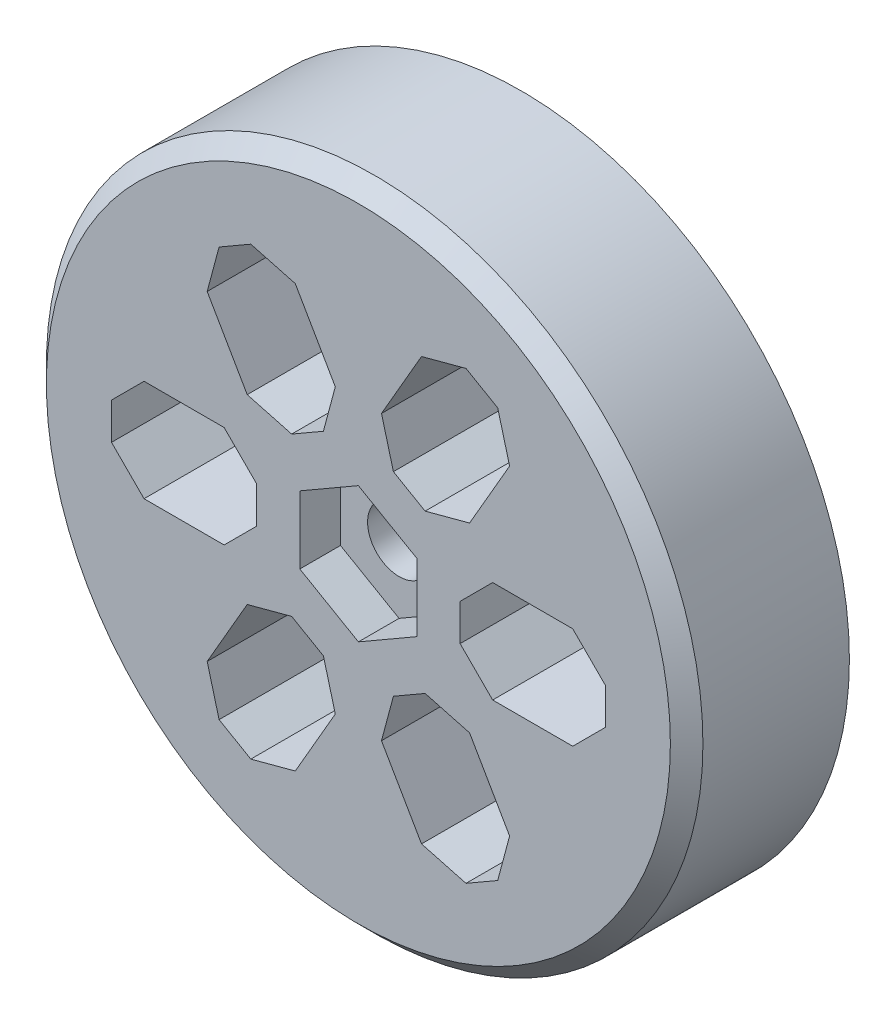
from build123d import *

# Parameters (mm, degrees)
SKETCH1_R               = 25.6159
BOSS_EXTRUDE1_DEPTH     = 12.7
CHAMFER1_SIZE           = 1.27
CUT_EXTRUDE1_DEPTH      = 3.175
F_8_CLEARANCE_HOLE1_D   = 4.9149
SKETCH5_W               = 11.3284
SKETCH5_H               = 7.9375
CUT_EXTRUDE_THIN1_DEPTH = 13.7
CHAMFER2_SIZE           = 2.54


with BuildPart() as part:
    # Sketch1 → Boss-Extrude1 (new body)
    with BuildSketch(Plane.XY):
        Circle(SKETCH1_R)
    extrude(amount=BOSS_EXTRUDE1_DEPTH)

    # Chamfer1
    chamfer1_edges = [part.edges().sort_by_distance(p)[0] for p in [
        (-25.6159, 0, 12.7),
    ]]
    chamfer(chamfer1_edges, length=CHAMFER1_SIZE)

    # Sketch2 → Cut-Extrude1 (cut)
    with BuildSketch(Plane.XY.offset(12.7)):
        Polygon((-4.572, -2.639645431), (0, -5.279290861), (4.572, -2.639645431), (4.572, 2.639645431), (0, 5.279290861), (-4.572, 2.639645431), align=None)
    extrude(amount=-CUT_EXTRUDE1_DEPTH, mode=Mode.SUBTRACT)

    # #8 Clearance Hole1 (through all)
    with Locations(Plane.XY.offset(12.7)):
        with Locations((0, 0)):
            Hole(F_8_CLEARANCE_HOLE1_D / 2)

    # Sketch5 → Cut-Extrude-Thin1 (cut, through all)
    with BuildSketch(Plane.XY.offset(12.7)):
        Polygon((-7.405788321, -4.889701643), (-13.069988321, -14.700383827), (-6.195911679, -18.669133827), (-0.531711679, -8.858451643), align=None)
        with Locations((-13.6017, 0)):
            Rectangle(SKETCH5_W, SKETCH5_H)
        Polygon((-0.531711679, 8.858451643), (-6.195911679, 18.669133827), (-13.069988321, 14.700383827), (-7.405788321, 4.889701643), align=None)
        Polygon((7.405788321, 4.889701643), (13.069988321, 14.700383827), (6.195911679, 18.669133827), (0.531711679, 8.858451643), align=None)
        with Locations((13.6017, 0)):
            Rectangle(SKETCH5_W, SKETCH5_H)
        Polygon((0.531711679, -8.858451643), (6.195911679, -18.669133827), (13.069988321, -14.700383827), (7.405788321, -4.889701643), align=None)
    extrude(amount=-CUT_EXTRUDE_THIN1_DEPTH, mode=Mode.SUBTRACT)

    # Chamfer2
    chamfer2_edges = [part.edges().sort_by_distance(p)[0] for p in [
        (6.195911679, -18.669133827, 6.35),
        (0.531711679, -8.858451643, 6.35),
        (7.405788321, -4.889701643, 6.35),
        (13.069988321, -14.700383827, 6.35),
        (19.2659, -3.96875, 6.35),
        (7.9375, -3.96875, 6.35),
        (7.9375, 3.96875, 6.35),
        (19.2659, 3.96875, 6.35),
        (13.069988321, 14.700383827, 6.35),
        (7.405788321, 4.889701643, 6.35),
        (0.531711679, 8.858451643, 6.35),
        (6.195911679, 18.669133827, 6.35),
        (-6.195911679, 18.669133827, 6.35),
        (-0.531711679, 8.858451643, 6.35),
        (-7.405788321, 4.889701643, 6.35),
        (-13.069988321, 14.700383827, 6.35),
        (-19.2659, 3.96875, 6.35),
        (-7.9375, 3.96875, 6.35),
        (-7.9375, -3.96875, 6.35),
        (-19.2659, -3.96875, 6.35),
        (-13.069988321, -14.700383827, 6.35),
        (-7.405788321, -4.889701643, 6.35),
        (-0.531711679, -8.858451643, 6.35),
        (-6.195911679, -18.669133827, 6.35),
    ]]
    chamfer(chamfer2_edges, length=CHAMFER2_SIZE)


solid = part.part
